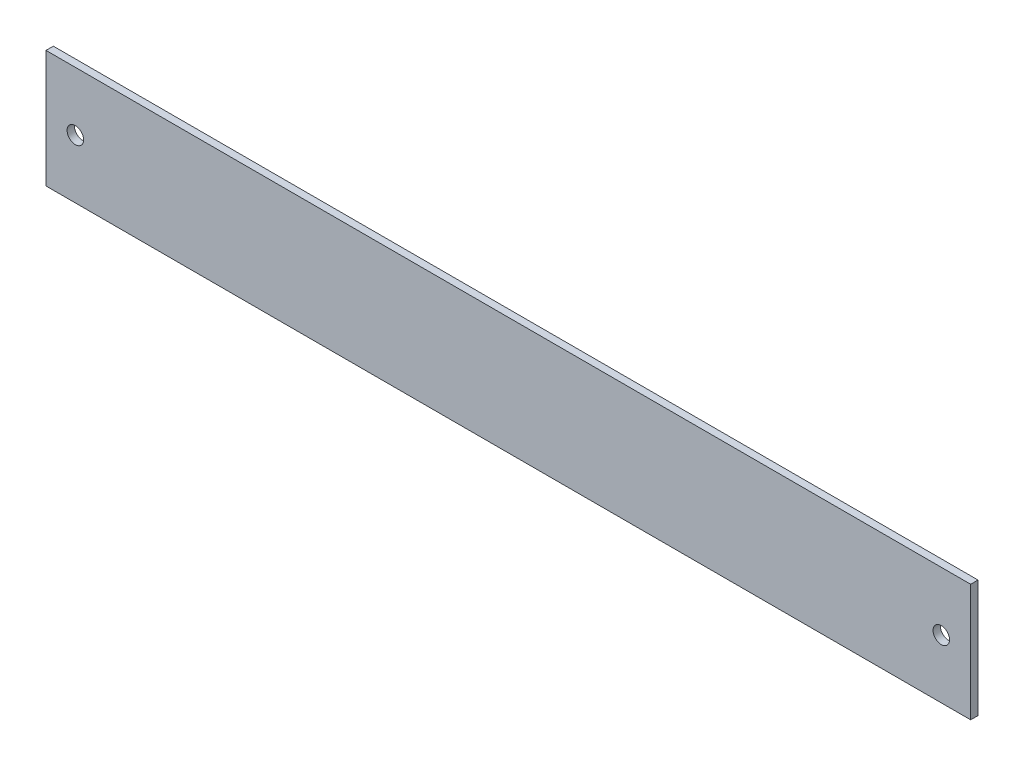
from build123d import *

# Parameters (mm, degrees)
SKETCH1_W           = 400
SKETCH1_H           = 50.8
BOSS_EXTRUDE1_DEPTH = 3.175
SKETCH2_R           = 3.5687
CUT_EXTRUDE1_DEPTH  = 4.175


with BuildPart() as part:
    # Sketch1 → Boss-Extrude1 (new body)
    with BuildSketch(Plane.XY):
        Rectangle(SKETCH1_W, SKETCH1_H)
    extrude(amount=BOSS_EXTRUDE1_DEPTH)

    # Sketch2 → Cut-Extrude1 (cut, through all)
    with BuildSketch(Plane.XY.offset(3.175)):
        with Locations((-187.3, 0)):
            Circle(SKETCH2_R)
        with Locations((187.3, 0)):
            Circle(SKETCH2_R)
    extrude(amount=-CUT_EXTRUDE1_DEPTH, mode=Mode.SUBTRACT)


solid = part.part
